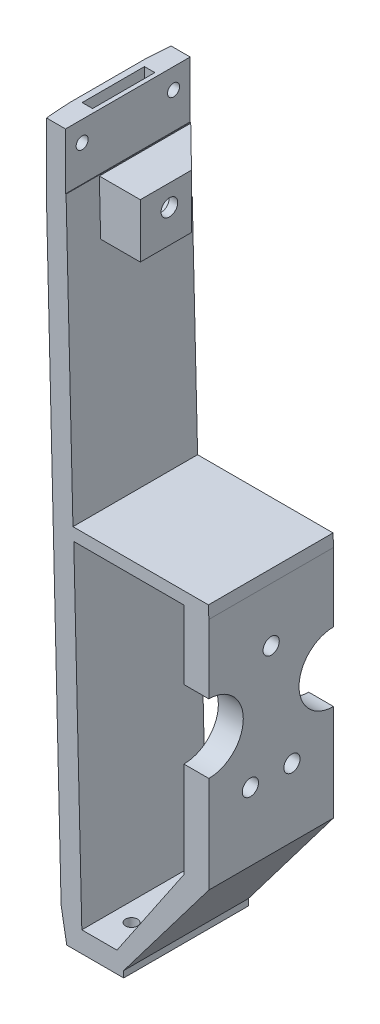
from build123d import *

# Parameters (mm, degrees)
EXTRUDE1_DEPTH                 = 30
EXTRUDE2_DEPTH                 = 30
SKETCH4_R                      = 8.288803623
EXTRUDE4_DEPTH                 = 30
SKETCH5_R                      = 1.95
EXTRUDE5_DEPTH                 = 20
SKETCH6_R                      = 1.95
EXTRUDE6_DEPTH                 = 20
SKETCH9_R                      = 1.45
EXTRUDE9_DEPTH                 = 20
EXTRUDE12_DEPTH                = 171
EXTRUDE15_START                = -4
EXTRUDE15_DEPTH                = 14
SKETCH17_W                     = 15
SKETCH17_H                     = 14.5
EXTRUDE17_DEPTH                = 4
SKETCH18_W                     = 2.5
SKETCH18_H                     = 15
EXTRUDE18_DEPTH                = 10
SKETCH19_W                     = 22
SKETCH19_H                     = 13
EXTRUDE19_DEPTH                = 10
SKETCH20_R                     = 4
EXTRUDE20_DEPTH                = 8.5
SKETCH21_R                     = 2
EXTRUDE21_DEPTH                = 9
EXTRUDE22_DEPTH                = 15
F_2_9_2_9_DIAMETER_HOLE1_D     = 2.9
F_2_9_2_9_DIAMETER_HOLE1_DEPTH = 10
EXTRUDE23_DEPTH                = 32


with BuildPart() as part:
    # Sketch1 → Extrude1 (new body)
    with BuildSketch(Plane.XY):
        Polygon((-0.863115633, -23.253389327), (14.136884367, -23.253389327), (14.136884367, -21.7046417), (34.636884367, 5.336278221), (34.636884367, 61.746610673), (28.636884367, 61.746610673), (28.636884367, 5.55848015), (12.519738096, -18.253389327), (-0.863115633, -18.253389327), align=None)
    extrude(amount=EXTRUDE1_DEPTH)

    # Sketch2 → Extrude2 (add)
    with BuildSketch(Plane.XY):
        Polygon((-0.863115633, -18.253389327), (-4.863115633, 146.746610673), (-0.063115633, 146.746610673), (0.136884367, 146.746610673), (0.136884367, 138.496610673), (1.925187517, 64.729105762), (34.532746461, 64.729105762), (34.636884367, 61.746610673), (28.636884367, 61.746610673), (2.118981118, 61.746610673), (4.058375057, -18.253389327), align=None)
    extrude(amount=EXTRUDE2_DEPTH)

    # Sketch4 → Extrude4 (cut)
    with BuildSketch(Plane(origin=(34.636884367, 0, 0), x_dir=(0, 0, -1), z_dir=(1, 0, 0))):
        with Locations((0, 36.886010892)):
            Circle(SKETCH4_R)
        with Locations((-30, 36.886010892)):
            Circle(SKETCH4_R)
    extrude(amount=-EXTRUDE4_DEPTH, mode=Mode.SUBTRACT)

    # Sketch5 → Extrude5 (cut)
    with BuildSketch(Plane(origin=(34.636884367, 0, 0), x_dir=(0, 0, -1), z_dir=(1, 0, 0))):
        with Locations((-20, 21.746610673)):
            Circle(SKETCH5_R)
        with Locations((-10, 21.746610673)):
            Circle(SKETCH5_R)
    extrude(amount=-EXTRUDE5_DEPTH, mode=Mode.SUBTRACT)

    # Sketch6 → Extrude6 (cut)
    with BuildSketch(Plane(origin=(34.636884367, 0, 0), x_dir=(0, 0, -1), z_dir=(1, 0, 0))):
        with Locations((-15, 48.746610673)):
            Circle(SKETCH6_R)
    extrude(amount=-EXTRUDE6_DEPTH, mode=Mode.SUBTRACT)

    # Sketch9 → Extrude9 (cut)
    with BuildSketch(Plane.XZ.offset(23.253389327)):
        with Locations((8.519738096, 7.5)):
            Circle(SKETCH9_R)
        with Locations((8.519738096, 22.5)):
            Circle(SKETCH9_R)
    extrude(amount=-EXTRUDE9_DEPTH, mode=Mode.SUBTRACT)

    # Sketch14 → Extrude12 (cut, through all)
    with BuildSketch(Plane(origin=(0, 146.746610673, 0), x_dir=(-1, 0, 0), z_dir=(0, 1, 0))):
        with BuildLine():
            Line((4.441840203, 0), (4.863115633, 0))
            Line((4.863115633, 0), (4.863115633, 6.019259174))
            add(Edge.make_bspline(
                [(4.441840203, 0), (4.519153962, 0.855924936), (4.700126089, 2.859430629), (4.803757165, 4.868494671), (4.863115633, 6.019259174)],
                knots=[0, 0, 0, 0, 0.427213628, 1, 1, 1, 1], degree=3))
        make_face()
    extrude12 = extrude(amount=-EXTRUDE12_DEPTH, mode=Mode.SUBTRACT)

    # Sketch15 → Extrude15 (cut)
    with BuildSketch(Plane(origin=(-1.713118599, -23.403267784, 0), x_dir=(-0.984807753, -0.173648178, 0), z_dir=(-0.173648178, 0.984807753, 0)).offset(EXTRUDE15_START)):
        with BuildLine():
            Line((-1.981754914, 15), (2.058740939, 15))
            Line((2.058740939, 15), (2.058740939, 30))
            Line((2.058740939, 30), (-2.130916258, 30))
            add(Edge.make_bspline(
                [(-2.130916258, 30), (-1.660064232, 28.72309887), (-0.852396925, 26.871960577), (-0.491380927, 22.662378444), (-1.504639477, 16.84253988), (-1.773156449, 15.805572323), (-1.981754914, 15)],
                knots=[0, 0, 0, 0, 0.210481429, 0.646187552, 0.725139409, 1, 1, 1, 1], degree=3))
        make_face()
    extrude15 = extrude(amount=EXTRUDE15_DEPTH, mode=Mode.SUBTRACT)

    # Sketch17 → Extrude17 (cut)
    with BuildSketch(Plane(origin=(-1.304855183, -0.031632853, 0), x_dir=(0, 0, 1), z_dir=(-0.999706282, -0.024235304, 0))):
        with Locations((15, 129.571367621)):
            Rectangle(SKETCH17_W, SKETCH17_H)
    extrude(amount=-EXTRUDE17_DEPTH, mode=Mode.SUBTRACT)

    # Sketch18 → Extrude18 (cut)
    with BuildSketch(Plane(origin=(-3.315907411, 136.781180707, 0), x_dir=(0.999706282, 0.024235304, 0), z_dir=(0.024235304, -0.999706282, 0))):
        with Locations((1.444761444, 15)):
            Rectangle(SKETCH18_W, SKETCH18_H)
    extrude(amount=-EXTRUDE18_DEPTH, mode=Mode.SUBTRACT)

    # Sketch19 → Extrude19 (add)
    with BuildSketch(Plane(origin=(0.136884367, 0, 0), x_dir=(0, 0, -1), z_dir=(1, 0, 0))):
        with Locations((-11, 126.496610673)):
            Rectangle(SKETCH19_W, SKETCH19_H)
    extrude(amount=EXTRUDE19_DEPTH)

    # Sketch20 → Extrude20 (cut)
    with BuildSketch(Plane(origin=(2.693969944, 0.065308362, 0), x_dir=(0, 0, 1), z_dir=(-0.999706282, -0.024235304, 0))):
        with Locations((15, 127.621367621)):
            Circle(SKETCH20_R)
    extrude(amount=-EXTRUDE20_DEPTH, mode=Mode.SUBTRACT)

    # Sketch21 → Extrude21 (cut)
    with BuildSketch(Plane(origin=(11.19147334, 0.271308445, 0), x_dir=(0, 0, 1), z_dir=(-0.999706282, -0.024235304, 0))):
        with Locations((15, 127.621367621)):
            Circle(SKETCH21_R)
    extrude(amount=-EXTRUDE21_DEPTH, mode=Mode.SUBTRACT)

    # Sketch22 → Extrude22 (cut)
    with BuildSketch(Plane(origin=(0, 132.996610673, 0), x_dir=(-1, 0, 0), z_dir=(0, 1, 0))):
        Polygon((-0.270217701, 0), (-10.136884367, 9.679287559), (-10.136884367, 0), align=None)
    extrude(amount=-EXTRUDE22_DEPTH, mode=Mode.SUBTRACT)

    # Mirror1: Extrude12 across plane
    add(extrude12.mirror(Plane.XY.offset(15)), mode=Mode.SUBTRACT)

    # Mirror2: Extrude15 across plane
    add(extrude15.mirror(Plane.XY.offset(15)), mode=Mode.SUBTRACT)

    # Ø2.9 (2.9) Diameter Hole1
    with Locations(Plane(origin=(-4.741939114, 141.748079264, 4), x_dir=(0.024235304, -0.999706282, 0), z_dir=(-0.999706282, -0.024235304, 0))):
        with Locations((0, 0)):
            f_2_9_2_9_diameter_hole1 = Hole(F_2_9_2_9_DIAMETER_HOLE1_D / 2, depth=F_2_9_2_9_DIAMETER_HOLE1_DEPTH)

    # Mirror3: Ø2.9 (2.9) Diameter Hole1 across plane
    add(f_2_9_2_9_diameter_hole1.mirror(Plane.XY.offset(15)), mode=Mode.SUBTRACT)

    # Sketch24 → Extrude23 (cut)
    with BuildSketch(Plane.XY.offset(30)):
        Polygon((0.136884367, 138.496610673), (0.136884367, 133.231496822), (0.638228483, 133.231496822), align=None)
    extrude(amount=-EXTRUDE23_DEPTH, mode=Mode.SUBTRACT)


solid = part.part
